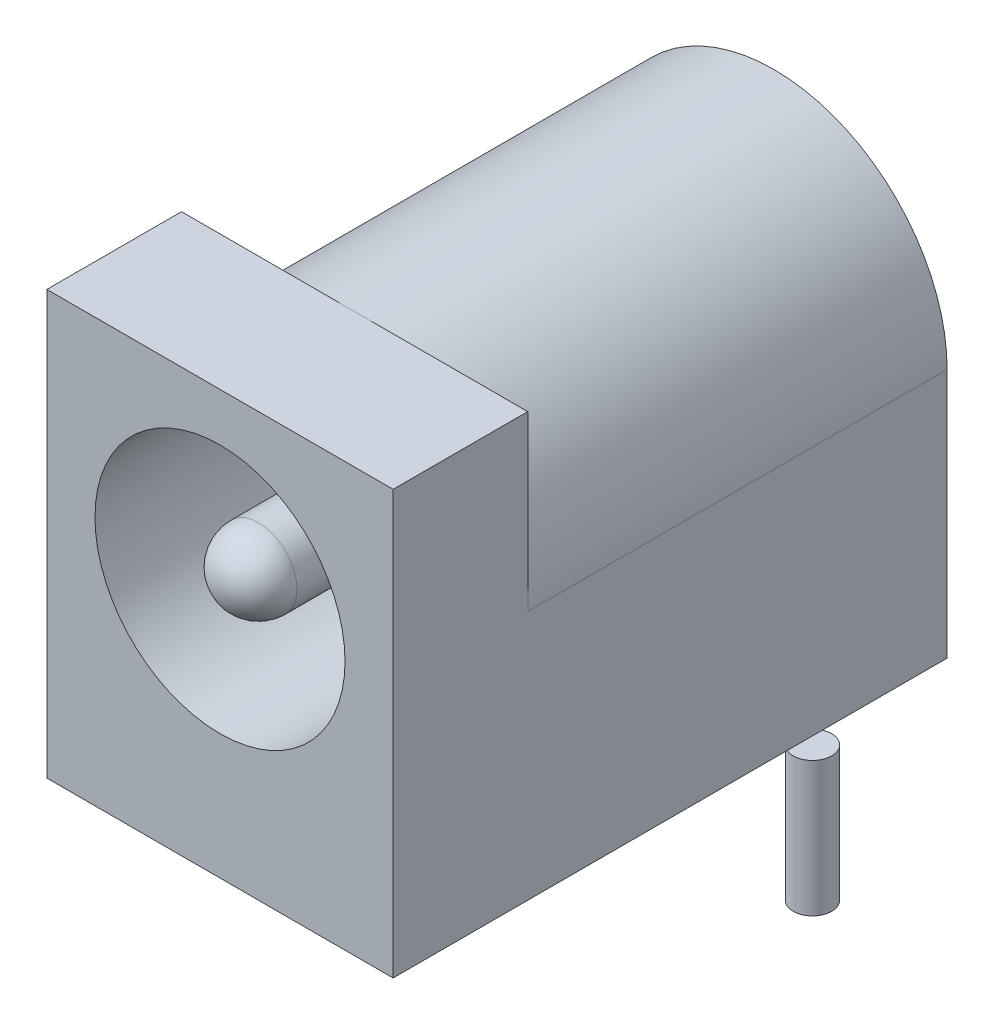
from build123d import *

# Parameters (mm, degrees)
BOSS_EXTRUDE1_DEPTH = 14.4
SKETCH3_W           = 9
SKETCH3_H           = 4.5
BOSS_EXTRUDE2_DEPTH = 3.5
SKETCH2_R           = 3.25
SKETCH2_R_2         = 1
CUT_EXTRUDE1_DEPTH  = 10
FILLET1_R           = 1
SKETCH4_R           = 0.5
BOSS_EXTRUDE3_DEPTH = 3.5


with BuildPart() as part:
    # Sketch1 → Boss-Extrude1 (new body)
    with BuildSketch(Plane.XY):
        with BuildLine():
            Line((4.5, 0), (-4.5, 0))
            Line((-4.5, 0), (-4.5, 6.5))
            ThreePointArc((-4.5, 6.5), (0, 11), (4.5, 6.5))
            Line((4.5, 6.5), (4.5, 0))
        make_face()
    extrude(amount=-BOSS_EXTRUDE1_DEPTH)

    # Sketch3 → Boss-Extrude2 (add)
    with BuildSketch(Plane.XY):
        with Locations((0, 8.75)):
            Rectangle(SKETCH3_W, SKETCH3_H)
    extrude(amount=-BOSS_EXTRUDE2_DEPTH)

    # Sketch2 → Cut-Extrude1 (cut)
    with BuildSketch(Plane.XY):
        with Locations((0, 6.5)):
            Circle(SKETCH2_R)
        with Locations((0, 6.5)):
            Circle(SKETCH2_R_2, mode=Mode.SUBTRACT)
    extrude(amount=-CUT_EXTRUDE1_DEPTH, mode=Mode.SUBTRACT)

    # Fillet1
    fillet1_edges = [part.edges().sort_by_distance(p)[0] for p in [
        (-1, 6.5, 0),
    ]]
    fillet(fillet1_edges, radius=FILLET1_R)

    # Sketch4 → Boss-Extrude3 (add)
    with BuildSketch(Plane.XZ):
        with Locations((0, -13.7)):
            Circle(SKETCH4_R)
        with Locations((0, -7.7)):
            Circle(SKETCH4_R)
        with Locations((4.7, -10.7)):
            Circle(SKETCH4_R)
    extrude(amount=BOSS_EXTRUDE3_DEPTH)


solid = part.part
